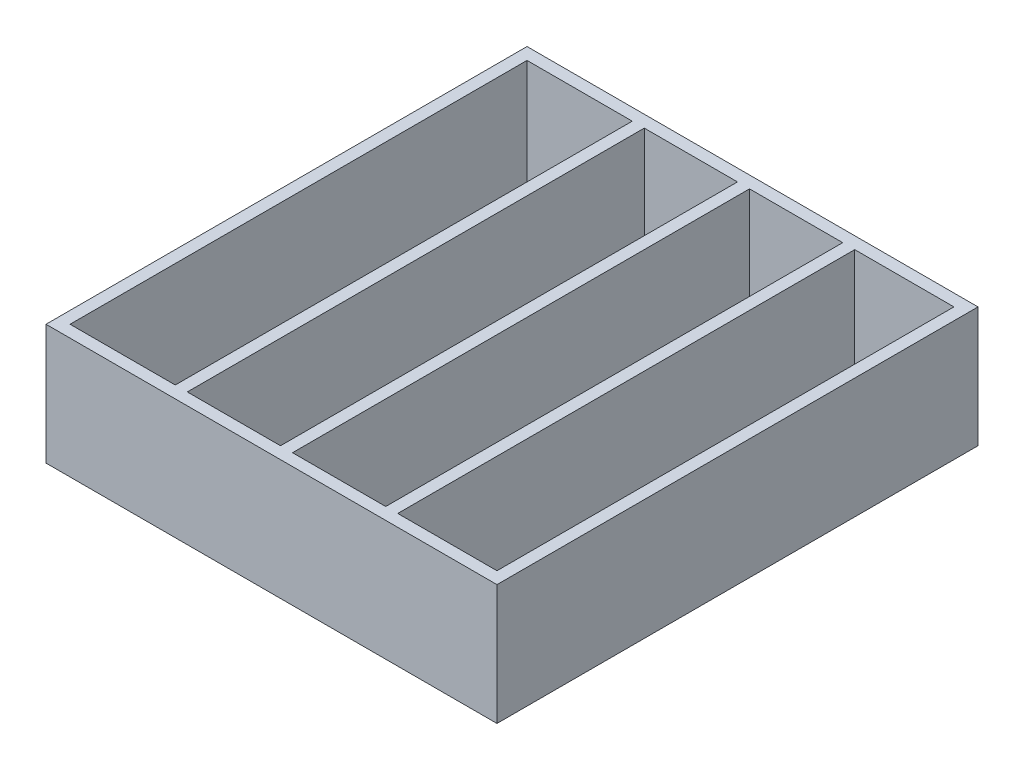
from build123d import *

# Parameters (mm, degrees)
SKETCH2_W           = 75
SKETCH2_H           = 80
SKETCH2_W_2         = 17.5
SKETCH2_H_2         = 76
SKETCH2_W_3         = 16.5
SKETCH2_W_4         = 15.5
BOSS_EXTRUDE1_DEPTH = 18
SKETCH3_W           = 75
SKETCH3_H           = 80
BOSS_EXTRUDE3_DEPTH = 2
SKETCH4_R           = 1.5
CUT_EXTRUDE1_DEPTH  = 3


with BuildPart() as part:
    # Sketch2 → Boss-Extrude1 (new body)
    with BuildSketch(Plane(origin=(0, 0, 0), x_dir=(1, 0, 0), z_dir=(0, 1, 0))):
        Rectangle(SKETCH2_W, SKETCH2_H)
        with Locations((-26.75, 0)):
            Rectangle(SKETCH2_W_2, SKETCH2_H_2, mode=Mode.SUBTRACT)
        with Locations((27.25, 0)):
            Rectangle(SKETCH2_W_3, SKETCH2_H_2, mode=Mode.SUBTRACT)
        with Locations((-8.25, 0)):
            Rectangle(SKETCH2_W_4, SKETCH2_H_2, mode=Mode.SUBTRACT)
        with Locations((9.25, 0)):
            Rectangle(SKETCH2_W_4, SKETCH2_H_2, mode=Mode.SUBTRACT)
    extrude(amount=BOSS_EXTRUDE1_DEPTH)

    # Sketch3 → Boss-Extrude3 (add)
    with BuildSketch(Plane.XZ):
        Rectangle(SKETCH3_W, SKETCH3_H)
    extrude(amount=BOSS_EXTRUDE3_DEPTH)

    # Sketch4 → Cut-Extrude1 (cut, through all)
    with BuildSketch(Plane(origin=(0, 0, 0), x_dir=(1, 0, 0), z_dir=(0, 1, 0))):
        with Locations((-26.75, -0.5)):
            Circle(SKETCH4_R)
    cut_extrude1 = extrude(amount=-CUT_EXTRUDE1_DEPTH, mode=Mode.SUBTRACT)

    # Mirror1: Cut-Extrude1 across plane
    add(cut_extrude1.mirror(Plane(origin=(0, 0, 0), x_dir=(0, 0, 1), z_dir=(1, 0, 0))), mode=Mode.SUBTRACT)


solid = part.part
